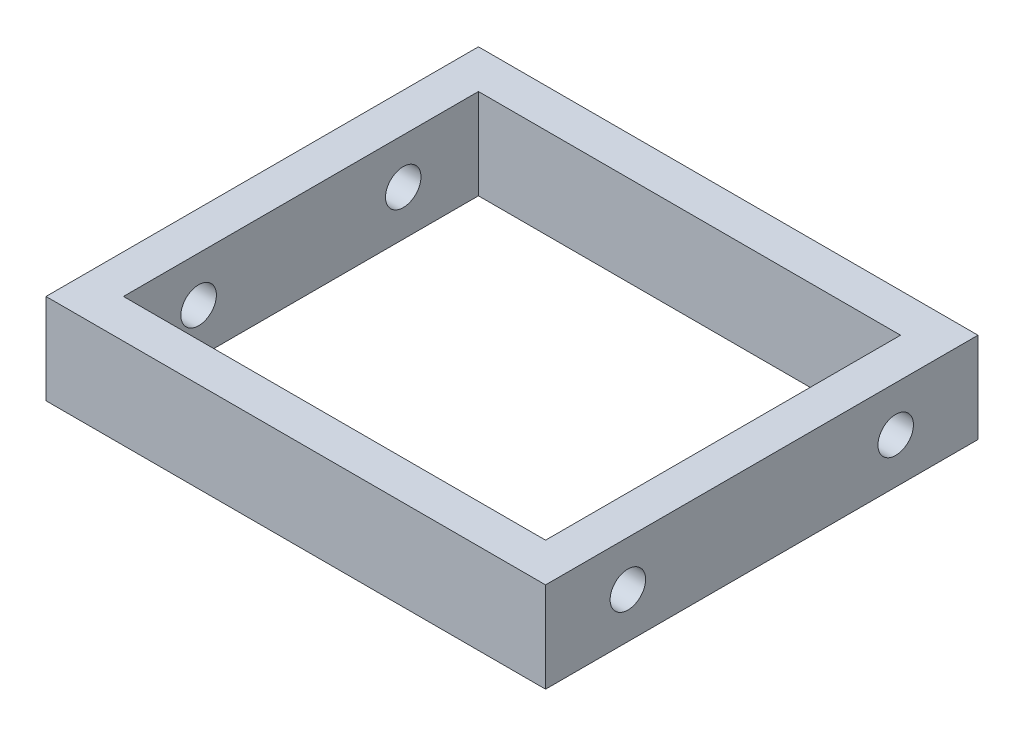
from build123d import *

# Parameters (mm, degrees)
SKETCH1_W           = 77.4
SKETCH1_H           = 67
SKETCH1_W_2         = 65.4
SKETCH1_H_2         = 55
BOSS_EXTRUDE1_DEPTH = 14
SKETCH2_R           = 2.75
CUT_EXTRUDE1_DEPTH  = 6
SKETCH3_R           = 2.75
CUT_EXTRUDE2_DEPTH  = 6


with BuildPart() as part:
    # Sketch1 → Boss-Extrude1 (new body)
    with BuildSketch(Plane(origin=(0, 0, 0), x_dir=(1, 0, 0), z_dir=(0, 1, 0))):
        Rectangle(SKETCH1_W, SKETCH1_H)
        Rectangle(SKETCH1_W_2, SKETCH1_H_2, mode=Mode.SUBTRACT)
    extrude(amount=BOSS_EXTRUDE1_DEPTH)

    # Sketch2 → Cut-Extrude1 (cut)
    with BuildSketch(Plane(origin=(38.7, 0, 0), x_dir=(0, 0, -1), z_dir=(1, 0, 0))):
        with Locations((-20.75, 7)):
            Circle(SKETCH2_R)
        with Locations((20.75, 7)):
            Circle(SKETCH2_R)
    extrude(amount=-CUT_EXTRUDE1_DEPTH, mode=Mode.SUBTRACT)

    # Sketch3 → Cut-Extrude2 (cut)
    with BuildSketch(Plane(origin=(-32.7, 0, 0), x_dir=(0, 0, -1), z_dir=(1, 0, 0))):
        with Locations((15.85, 7)):
            Circle(SKETCH3_R)
        with Locations((-15.85, 7)):
            Circle(SKETCH3_R)
    extrude(amount=-CUT_EXTRUDE2_DEPTH, mode=Mode.SUBTRACT)


solid = part.part
